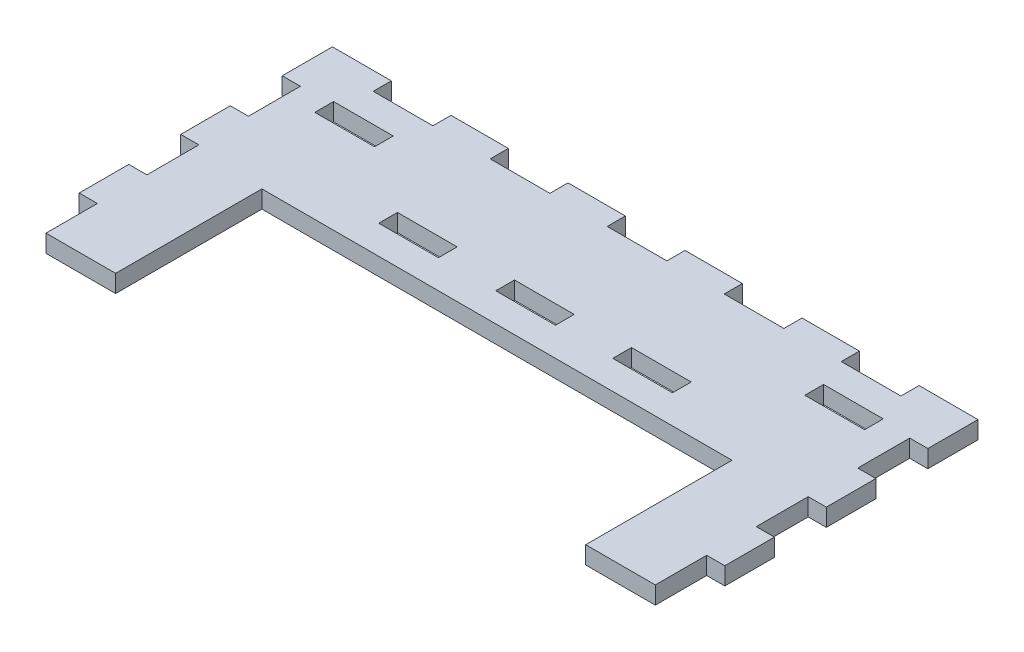
from build123d import *

# Parameters (mm, degrees)
BOSS_EXTRUDE1_DEPTH = 3
SKETCH4_W           = 10.2
SKETCH4_H           = 3.2
SKETCH4_W_2         = 3.2
SKETCH4_H_2         = 8.875
CUT_EXTRUDE1_DEPTH  = 4


with BuildPart() as part:
    # Sketch1 → Boss-Extrude1 (new body)
    with BuildSketch(Plane(origin=(0, 0, 0), x_dir=(1, 0, 0), z_dir=(0, 1, 0))):
        Polygon((-55.172217102, 52.05), (55.172217102, 52.05), (55.172217102, 0), (40.172217102, 0), (40.172217102, 25), (-40.172217102, 25), (-40.172217102, 0), (-55.172217102, 0), align=None)
    extrude(amount=BOSS_EXTRUDE1_DEPTH)

    # Sketch4 → Cut-Extrude1 (cut, through all)
    with BuildSketch(Plane(origin=(0, 0, 0), x_dir=(1, 0, 0), z_dir=(0, 1, 0))):
        with Locations((40, 50.55)):
            Rectangle(SKETCH4_W, SKETCH4_H)
        with Locations((41.872217102, 42.45)):
            Rectangle(SKETCH4_W, SKETCH4_H)
        with Locations((53.672217102, 39.0375)):
            Rectangle(SKETCH4_W_2, SKETCH4_H_2)
        with Locations((53.672217102, 21.6875)):
            Rectangle(SKETCH4_W_2, SKETCH4_H_2)
        with Locations((53.672217102, 4.3375)):
            Rectangle(SKETCH4_W_2, SKETCH4_H_2)
        with Locations((20, 31.5)):
            Rectangle(SKETCH4_W, SKETCH4_H)
        with Locations((0, 31.5)):
            Rectangle(SKETCH4_W, SKETCH4_H)
        with Locations((20, 50.55)):
            Rectangle(SKETCH4_W, SKETCH4_H)
        with Locations((-53.672217102, 4.3375)):
            Rectangle(SKETCH4_W_2, SKETCH4_H_2)
        with Locations((-53.672217102, 21.6875)):
            Rectangle(SKETCH4_W_2, SKETCH4_H_2)
        with Locations((-53.672217102, 39.0375)):
            Rectangle(SKETCH4_W_2, SKETCH4_H_2)
        with Locations((-40, 50.55)):
            Rectangle(SKETCH4_W, SKETCH4_H)
        with Locations((-41.872217102, 42.45)):
            Rectangle(SKETCH4_W, SKETCH4_H)
        with Locations((0, 50.55)):
            Rectangle(SKETCH4_W, SKETCH4_H)
        with Locations((-20, 31.5)):
            Rectangle(SKETCH4_W, SKETCH4_H)
        with Locations((-20, 50.55)):
            Rectangle(SKETCH4_W, SKETCH4_H)
    extrude(amount=CUT_EXTRUDE1_DEPTH, mode=Mode.SUBTRACT)


solid = part.part
